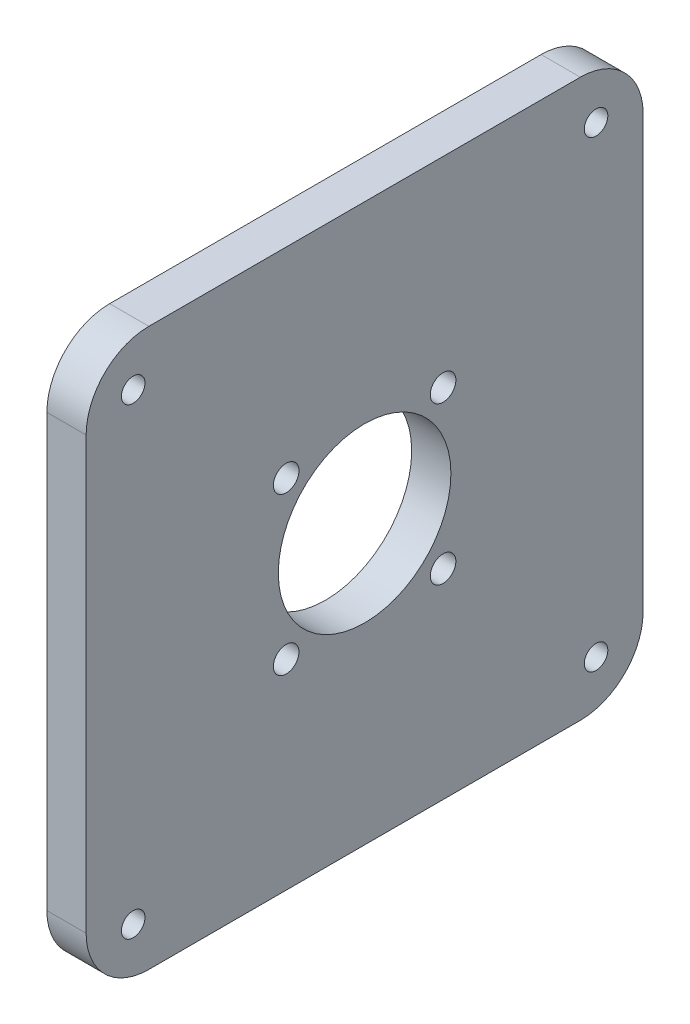
from build123d import *

# Parameters (mm, degrees)
SKETCH1_W           = 71
SKETCH1_H           = 71
SKETCH1_R           = 1.5
SKETCH1_R_2         = 11
SKETCH1_R_3         = 1.631951877
BOSS_EXTRUDE1_DEPTH = 5
FILLET1_R           = 8


with BuildPart() as part:
    # Sketch1 → Boss-Extrude1 (new body)
    with BuildSketch(Plane(origin=(0, 0, 0), x_dir=(0, 0, -1), z_dir=(1, 0, 0))):
        with Locations((35.5, 35.5)):
            Rectangle(SKETCH1_W, SKETCH1_H)
        with Locations((6, 6)):
            Circle(SKETCH1_R, mode=Mode.SUBTRACT)
        with Locations((6, 65)):
            Circle(SKETCH1_R, mode=Mode.SUBTRACT)
        with Locations((65, 65)):
            Circle(SKETCH1_R, mode=Mode.SUBTRACT)
        with Locations((65, 6)):
            Circle(SKETCH1_R, mode=Mode.SUBTRACT)
        with Locations((35.5, 35.5)):
            Circle(SKETCH1_R_2, mode=Mode.SUBTRACT)
        with Locations((25.5, 45.5)):
            Circle(SKETCH1_R_3, mode=Mode.SUBTRACT)
        with Locations((45.5, 45.5)):
            Circle(SKETCH1_R_3, mode=Mode.SUBTRACT)
        with Locations((25.5, 25.5)):
            Circle(SKETCH1_R_3, mode=Mode.SUBTRACT)
        with Locations((45.5, 25.5)):
            Circle(SKETCH1_R_3, mode=Mode.SUBTRACT)
    extrude(amount=BOSS_EXTRUDE1_DEPTH)

    # Fillet1
    fillet1_edges = [part.edges().sort_by_distance(p)[0] for p in [
        (2.5, 71, 0),
        (2.5, 71, -71),
        (2.5, 0, -71),
        (2.5, 0, 0),
    ]]
    fillet(fillet1_edges, radius=FILLET1_R)


solid = part.part
